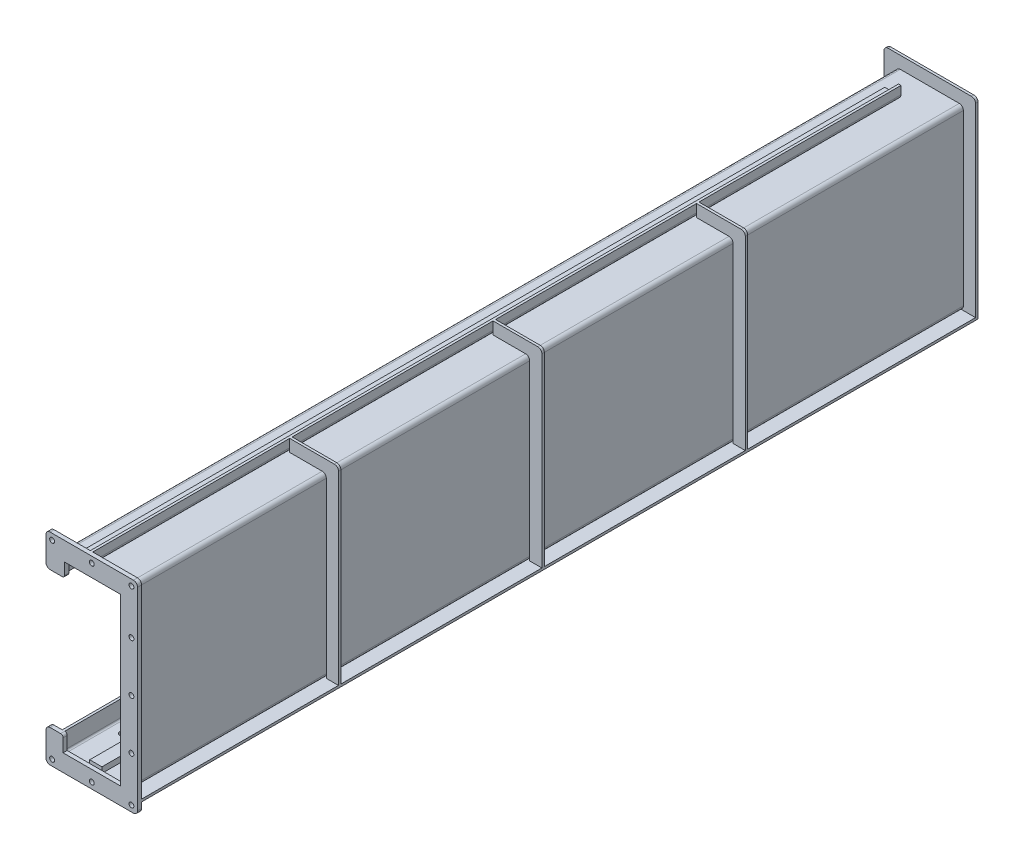
from build123d import *

# Parameters (mm, degrees)
EXTRUDE_1_DEPTH     = 2050
EXTRUDE_2_DEPTH     = 10
SKETCH_3_W          = 40
SKETCH_3_H          = 1986.707861461
EXTRUDE_3_DEPTH     = 6
SKETCH_4_W          = 6
SKETCH_4_H          = 1986.707861461
EXTRUDE_4_DEPTH     = 24
FILLET_1_R          = 4
FILLET_2_R          = 10
EXTRUDE_5_DEPTH     = 6
EXTRUDE_6_DEPTH     = 6
EXTRUDE_7_DEPTH     = 6
EXTRUDE_8_DEPTH     = 6
SKETCH_9_W          = 180
SKETCH_9_H          = 2056
EXTRUDE_9_DEPTH     = 6
SKETCH_10_W         = 30
SKETCH_10_H         = 14
EXTRUDE_10_DEPTH    = 2056
FILLET_3_R          = 10
FILLET_4_R          = 6
CUT_EXTRUDE_1_REACH = 38
SKETCH_11_R         = 7
SKETCH_12_R         = 6
SKETCH_12_W         = 5695
SKETCH_12_H         = 334
CUT_EXTRUDE_2_DEPTH = 10


with BuildPart() as part:
    # 草图1 → 凸台-拉伸1 (new body)
    with BuildSketch(Plane.XY):
        with BuildLine():
            Line((0, 10), (0, 426))
            ThreePointArc((0, 426), (-2.928932188, 433.071067812), (-10, 436))
            Line((-10, 436), (-155, 436))
            ThreePointArc((-155, 436), (-162.071067812, 433.071067812), (-165, 426))
            Line((-165, 426), (-165, 386))
            Line((-165, 386), (-159, 386))
            Line((-159, 386), (-159, 426))
            ThreePointArc((-159, 426), (-157.828427125, 428.828427125), (-155, 430))
            Line((-155, 430), (-10, 430))
            ThreePointArc((-10, 430), (-7.171572875, 428.828427125), (-6, 426))
            Line((-6, 426), (-6, 10))
            ThreePointArc((-6, 10), (-7.171572875, 7.171572875), (-10, 6))
            Line((-10, 6), (-155, 6))
            ThreePointArc((-155, 6), (-157.828427125, 7.171572875), (-159, 10))
            Line((-159, 10), (-159, 50))
            Line((-159, 50), (-165, 50))
            Line((-165, 50), (-165, 10))
            ThreePointArc((-165, 10), (-162.071067812, 2.928932188), (-155, 0))
            Line((-155, 0), (-10, 0))
            ThreePointArc((-10, 0), (-2.928932188, 2.928932188), (0, 10))
        make_face()
    extrude(amount=EXTRUDE_1_DEPTH)



with BuildPart() as body_2:
    # 草图2 → 凸台-拉伸2 (new body)
    with BuildSketch(Plane.XY.offset(2050)):
        with BuildLine():
            Line((-153, 50), (-195, 50))
            Line((-195, 50), (-195, -20))
            ThreePointArc((-195, -20), (-192.071067812, -27.071067812), (-185, -30))
            Line((-185, -30), (20, -30))
            ThreePointArc((20, -30), (27.071067812, -27.071067812), (30, -20))
            Line((30, -20), (30, 456))
            ThreePointArc((30, 456), (27.071067812, 463.071067812), (20, 466))
            Line((20, 466), (-185.000001669, 466))
            ThreePointArc((-185.000001669, 466), (-192.071069481, 463.071067812), (-195.000001669, 456))
            Line((-195.000001669, 456), (-195.000001669, 386))
            Line((-195.000001669, 386), (-149, 386))
            Line((-149, 386), (-149, 420))
            Line((-149, 420), (-12, 420))
            Line((-12, 420), (-12, 12))
            Line((-12, 12), (-153, 12))
            Line((-153, 12), (-153, 50))
        make_face()
    extrude(amount=EXTRUDE_2_DEPTH)



with BuildPart() as body_3:
    # 草图3 → 凸台-拉伸3 (new body)
    with BuildSketch(Plane(origin=(0, 436, 0), x_dir=(1, 0, 0), z_dir=(0, 1, 0))):
        with Locations((-110, -1056.64606927)):
            Rectangle(SKETCH_3_W, SKETCH_3_H)
    extrude(amount=EXTRUDE_3_DEPTH)


with BuildPart() as body_2_1:
    add(body_2.part)

    add(body_3.part)  # 凸台-拉伸4 merges body 3
    # 草图4 → 凸台-拉伸4 (add)
    with BuildSketch(Plane(origin=(0, 442, 0), x_dir=(1, 0, 0), z_dir=(0, 1, 0))):
        with Locations((-93, -1056.64606927)):
            Rectangle(SKETCH_4_W, SKETCH_4_H)
    extrude(amount=EXTRUDE_4_DEPTH)

    # 圆角1
    fillet_1_edges = [body_2_1.edges().sort_by_distance(p)[0] for p in [
        (-96, 442, 1056.64606927),
    ]]
    fillet(fillet_1_edges, radius=FILLET_1_R)

    # 圆角2
    fillet_2_edges = [body_2_1.edges().sort_by_distance(p)[0] for p in [
        (-90, 436, 1056.64606927),
    ]]
    fillet(fillet_2_edges, radius=FILLET_2_R)


with BuildPart() as part_1:
    add(part.part)

    add(body_2_1.part)  # 凸台-拉伸5 merges body 2
    # 草图5 → 凸台-拉伸5 (add)
    with BuildSketch(Plane.XY.offset(1560)):
        with BuildLine():
            Line((0, 0), (30, 0))
            Line((30, 0), (30, 456))
            ThreePointArc((30, 456), (27.071067812, 463.071067812), (20, 466))
            Line((20, 466), (-90, 466))
            Line((-90, 466), (-90, 436))
            Line((-90, 436), (-10, 436))
            ThreePointArc((-10, 436), (-2.928932188, 433.071067812), (0, 426))
            Line((0, 426), (0, 0))
        make_face()
    extrude(amount=EXTRUDE_5_DEPTH)

    # 草图6 → 凸台-拉伸6 (add)
    with BuildSketch(Plane.XY.offset(1060)):
        with BuildLine():
            Line((-90, 436), (-10, 436))
            ThreePointArc((-10, 436), (-2.928932188, 433.071067812), (0, 426))
            Line((0, 426), (0, 10))
            Line((0, 10), (0, 0))
            Line((0, 0), (30, 0))
            Line((30, 0), (30, 456))
            ThreePointArc((30, 456), (27.071067812, 463.071067812), (20, 466))
            Line((20, 466), (-90, 466))
            Line((-90, 466), (-90, 446))
            Line((-90, 446), (-90, 436))
        make_face()
    extrude(amount=EXTRUDE_6_DEPTH)

    # 草图7 → 凸台-拉伸7 (add)
    with BuildSketch(Plane.XY.offset(560)):
        with BuildLine():
            Line((0, 426), (0, 10))
            Line((0, 10), (0, 0))
            Line((0, 0), (30, 0))
            Line((30, 0), (30, 456))
            ThreePointArc((30, 456), (27.071067812, 463.071067812), (20, 466))
            Line((20, 466), (-90, 466))
            Line((-90, 466), (-90, 446))
            Line((-90, 446), (-90, 436))
            Line((-90, 436), (-10, 436))
            ThreePointArc((-10, 436), (-2.928932188, 433.071067812), (0, 426))
        make_face()
    extrude(amount=EXTRUDE_7_DEPTH)

    # 草图8 → 凸台-拉伸8 (add)
    with BuildSketch(Plane(origin=(0, 0, 0), x_dir=(-1, 0, 0), z_dir=(0, 0, -1))):
        with BuildLine():
            Line((0, 0), (-30, 0))
            Line((-30, 0), (-30, 456))
            ThreePointArc((-30, 456), (-27.071067812, 463.071067812), (-20, 466))
            Line((-20, 466), (185.000001669, 466))
            ThreePointArc((185.000001669, 466), (192.071069481, 463.071067812), (195.000001669, 456))
            Line((195.000001669, 456), (195.000001669, 386))
            Line((195.000001669, 386), (149, 386))
            Line((149, 386), (149, 420))
            Line((149, 420), (12, 420))
            Line((12, 420), (12, 12))
            Line((12, 12), (153, 12))
            Line((153, 12), (153, 50))
            Line((153, 50), (195, 50))
            Line((195, 50), (195, 0))
            Line((195, 0), (0, 0))
        make_face()
    extrude(amount=EXTRUDE_8_DEPTH)

    # 草图9 → 凸台-拉伸9 (add)
    with BuildSketch(Plane.XZ):
        with Locations((-60, 1022)):
            Rectangle(SKETCH_9_W, SKETCH_9_H)
    extrude(amount=EXTRUDE_9_DEPTH)

    # 草图10 → 凸台-拉伸10 (add)
    with BuildSketch(Plane.XY.offset(2050)):
        with Locations((-82.5, 423)):
            Rectangle(SKETCH_10_W, SKETCH_10_H)
        with Locations((-82.5, 13)):
            Rectangle(SKETCH_10_W, SKETCH_10_H)
    extrude(amount=-EXTRUDE_10_DEPTH)

    # 圆角3
    fillet_3_edges = [part_1.edges().sort_by_distance(p)[0] for p in [
        (-195, 50, 2055),
        (-195.000001669, 386, 2055),
    ]]
    fillet(fillet_3_edges, radius=FILLET_3_R)

    # 圆角4
    fillet_4_edges = [part_1.edges().sort_by_distance(p)[0] for p in [
        (-153, 50, 2055),
        (-149, 386, 2055),
    ]]
    fillet(fillet_4_edges, radius=FILLET_4_R)

    # 草图11 → 切除-拉伸1 (cut, up to next)
    with BuildSketch(Plane(origin=(0, 6, 0), x_dir=(1, 0, 0), z_dir=(0, 1, 0)), mode=Mode.PRIVATE) as cut_extrude_1_sk1:
        with Locations((-37.5, -1940)):
            Circle(SKETCH_11_R)
    cut_extrude_1_tool1 = extrude(cut_extrude_1_sk1.sketch, amount=-CUT_EXTRUDE_1_REACH, mode=Mode.PRIVATE) & part_1.part
    add(cut_extrude_1_tool1.solids().sort_by_distance((-37.5, 6, 1940))[0], mode=Mode.SUBTRACT)
    # 草图11 → 切除-拉伸1 (cut, up to next)
    with BuildSketch(Plane(origin=(0, 6, 0), x_dir=(1, 0, 0), z_dir=(0, 1, 0)), mode=Mode.PRIVATE) as cut_extrude_1_sk2:
        with Locations((-127.5, -1940)):
            Circle(SKETCH_11_R)
    cut_extrude_1_tool2 = extrude(cut_extrude_1_sk2.sketch, amount=-CUT_EXTRUDE_1_REACH, mode=Mode.PRIVATE) & part_1.part
    add(cut_extrude_1_tool2.solids().sort_by_distance((-127.5, 6, 1940))[0], mode=Mode.SUBTRACT)
    # 草图11 → 切除-拉伸1 (cut, up to next)
    with BuildSketch(Plane(origin=(0, 6, 0), x_dir=(1, 0, 0), z_dir=(0, 1, 0)), mode=Mode.PRIVATE) as cut_extrude_1_sk3:
        with Locations((-37.5, -1700)):
            Circle(SKETCH_11_R)
    cut_extrude_1_tool3 = extrude(cut_extrude_1_sk3.sketch, amount=-CUT_EXTRUDE_1_REACH, mode=Mode.PRIVATE) & part_1.part
    add(cut_extrude_1_tool3.solids().sort_by_distance((-37.5, 6, 1700))[0], mode=Mode.SUBTRACT)
    # 草图11 → 切除-拉伸1 (cut, up to next)
    with BuildSketch(Plane(origin=(0, 6, 0), x_dir=(1, 0, 0), z_dir=(0, 1, 0)), mode=Mode.PRIVATE) as cut_extrude_1_sk4:
        with Locations((-127.5, -1700)):
            Circle(SKETCH_11_R)
    cut_extrude_1_tool4 = extrude(cut_extrude_1_sk4.sketch, amount=-CUT_EXTRUDE_1_REACH, mode=Mode.PRIVATE) & part_1.part
    add(cut_extrude_1_tool4.solids().sort_by_distance((-127.5, 6, 1700))[0], mode=Mode.SUBTRACT)
    # 草图11 → 切除-拉伸1 (cut, up to next)
    with BuildSketch(Plane(origin=(0, 6, 0), x_dir=(1, 0, 0), z_dir=(0, 1, 0)), mode=Mode.PRIVATE) as cut_extrude_1_sk5:
        with Locations((-37.5, -1460)):
            Circle(SKETCH_11_R)
    cut_extrude_1_tool5 = extrude(cut_extrude_1_sk5.sketch, amount=-CUT_EXTRUDE_1_REACH, mode=Mode.PRIVATE) & part_1.part
    add(cut_extrude_1_tool5.solids().sort_by_distance((-37.5, 6, 1460))[0], mode=Mode.SUBTRACT)
    # 草图11 → 切除-拉伸1 (cut, up to next)
    with BuildSketch(Plane(origin=(0, 6, 0), x_dir=(1, 0, 0), z_dir=(0, 1, 0)), mode=Mode.PRIVATE) as cut_extrude_1_sk6:
        with Locations((-127.5, -1460)):
            Circle(SKETCH_11_R)
    cut_extrude_1_tool6 = extrude(cut_extrude_1_sk6.sketch, amount=-CUT_EXTRUDE_1_REACH, mode=Mode.PRIVATE) & part_1.part
    add(cut_extrude_1_tool6.solids().sort_by_distance((-127.5, 6, 1460))[0], mode=Mode.SUBTRACT)
    # 草图11 → 切除-拉伸1 (cut, up to next)
    with BuildSketch(Plane(origin=(0, 6, 0), x_dir=(1, 0, 0), z_dir=(0, 1, 0)), mode=Mode.PRIVATE) as cut_extrude_1_sk7:
        with Locations((-37.5, -1220)):
            Circle(SKETCH_11_R)
    cut_extrude_1_tool7 = extrude(cut_extrude_1_sk7.sketch, amount=-CUT_EXTRUDE_1_REACH, mode=Mode.PRIVATE) & part_1.part
    add(cut_extrude_1_tool7.solids().sort_by_distance((-37.5, 6, 1220))[0], mode=Mode.SUBTRACT)
    # 草图11 → 切除-拉伸1 (cut, up to next)
    with BuildSketch(Plane(origin=(0, 6, 0), x_dir=(1, 0, 0), z_dir=(0, 1, 0)), mode=Mode.PRIVATE) as cut_extrude_1_sk8:
        with Locations((-127.5, -1220)):
            Circle(SKETCH_11_R)
    cut_extrude_1_tool8 = extrude(cut_extrude_1_sk8.sketch, amount=-CUT_EXTRUDE_1_REACH, mode=Mode.PRIVATE) & part_1.part
    add(cut_extrude_1_tool8.solids().sort_by_distance((-127.5, 6, 1220))[0], mode=Mode.SUBTRACT)
    # 草图11 → 切除-拉伸1 (cut, up to next)
    with BuildSketch(Plane(origin=(0, 6, 0), x_dir=(1, 0, 0), z_dir=(0, 1, 0)), mode=Mode.PRIVATE) as cut_extrude_1_sk9:
        with Locations((-37.5, -980)):
            Circle(SKETCH_11_R)
    cut_extrude_1_tool9 = extrude(cut_extrude_1_sk9.sketch, amount=-CUT_EXTRUDE_1_REACH, mode=Mode.PRIVATE) & part_1.part
    add(cut_extrude_1_tool9.solids().sort_by_distance((-37.5, 6, 980))[0], mode=Mode.SUBTRACT)
    # 草图11 → 切除-拉伸1 (cut, up to next)
    with BuildSketch(Plane(origin=(0, 6, 0), x_dir=(1, 0, 0), z_dir=(0, 1, 0)), mode=Mode.PRIVATE) as cut_extrude_1_sk10:
        with Locations((-127.5, -980)):
            Circle(SKETCH_11_R)
    cut_extrude_1_tool10 = extrude(cut_extrude_1_sk10.sketch, amount=-CUT_EXTRUDE_1_REACH, mode=Mode.PRIVATE) & part_1.part
    add(cut_extrude_1_tool10.solids().sort_by_distance((-127.5, 6, 980))[0], mode=Mode.SUBTRACT)
    # 草图11 → 切除-拉伸1 (cut, up to next)
    with BuildSketch(Plane(origin=(0, 6, 0), x_dir=(1, 0, 0), z_dir=(0, 1, 0)), mode=Mode.PRIVATE) as cut_extrude_1_sk11:
        with Locations((-37.5, -740)):
            Circle(SKETCH_11_R)
    cut_extrude_1_tool11 = extrude(cut_extrude_1_sk11.sketch, amount=-CUT_EXTRUDE_1_REACH, mode=Mode.PRIVATE) & part_1.part
    add(cut_extrude_1_tool11.solids().sort_by_distance((-37.5, 6, 740))[0], mode=Mode.SUBTRACT)
    # 草图11 → 切除-拉伸1 (cut, up to next)
    with BuildSketch(Plane(origin=(0, 6, 0), x_dir=(1, 0, 0), z_dir=(0, 1, 0)), mode=Mode.PRIVATE) as cut_extrude_1_sk12:
        with Locations((-127.5, -740)):
            Circle(SKETCH_11_R)
    cut_extrude_1_tool12 = extrude(cut_extrude_1_sk12.sketch, amount=-CUT_EXTRUDE_1_REACH, mode=Mode.PRIVATE) & part_1.part
    add(cut_extrude_1_tool12.solids().sort_by_distance((-127.5, 6, 740))[0], mode=Mode.SUBTRACT)
    # 草图11 → 切除-拉伸1 (cut, up to next)
    with BuildSketch(Plane(origin=(0, 6, 0), x_dir=(1, 0, 0), z_dir=(0, 1, 0)), mode=Mode.PRIVATE) as cut_extrude_1_sk13:
        with Locations((-37.5, -500)):
            Circle(SKETCH_11_R)
    cut_extrude_1_tool13 = extrude(cut_extrude_1_sk13.sketch, amount=-CUT_EXTRUDE_1_REACH, mode=Mode.PRIVATE) & part_1.part
    add(cut_extrude_1_tool13.solids().sort_by_distance((-37.5, 6, 500))[0], mode=Mode.SUBTRACT)
    # 草图11 → 切除-拉伸1 (cut, up to next)
    with BuildSketch(Plane(origin=(0, 6, 0), x_dir=(1, 0, 0), z_dir=(0, 1, 0)), mode=Mode.PRIVATE) as cut_extrude_1_sk14:
        with Locations((-127.5, -500)):
            Circle(SKETCH_11_R)
    cut_extrude_1_tool14 = extrude(cut_extrude_1_sk14.sketch, amount=-CUT_EXTRUDE_1_REACH, mode=Mode.PRIVATE) & part_1.part
    add(cut_extrude_1_tool14.solids().sort_by_distance((-127.5, 6, 500))[0], mode=Mode.SUBTRACT)
    # 草图11 → 切除-拉伸1 (cut, up to next)
    with BuildSketch(Plane(origin=(0, 6, 0), x_dir=(1, 0, 0), z_dir=(0, 1, 0)), mode=Mode.PRIVATE) as cut_extrude_1_sk15:
        with Locations((-37.5, -260)):
            Circle(SKETCH_11_R)
    cut_extrude_1_tool15 = extrude(cut_extrude_1_sk15.sketch, amount=-CUT_EXTRUDE_1_REACH, mode=Mode.PRIVATE) & part_1.part
    add(cut_extrude_1_tool15.solids().sort_by_distance((-37.5, 6, 260))[0], mode=Mode.SUBTRACT)
    # 草图11 → 切除-拉伸1 (cut, up to next)
    with BuildSketch(Plane(origin=(0, 6, 0), x_dir=(1, 0, 0), z_dir=(0, 1, 0)), mode=Mode.PRIVATE) as cut_extrude_1_sk16:
        with Locations((-127.5, -260)):
            Circle(SKETCH_11_R)
    cut_extrude_1_tool16 = extrude(cut_extrude_1_sk16.sketch, amount=-CUT_EXTRUDE_1_REACH, mode=Mode.PRIVATE) & part_1.part
    add(cut_extrude_1_tool16.solids().sort_by_distance((-127.5, 6, 260))[0], mode=Mode.SUBTRACT)
    # 草图11 → 切除-拉伸1 (cut, up to next)
    with BuildSketch(Plane(origin=(0, 6, 0), x_dir=(1, 0, 0), z_dir=(0, 1, 0)), mode=Mode.PRIVATE) as cut_extrude_1_sk17:
        with Locations((-37.5, -20)):
            Circle(SKETCH_11_R)
    cut_extrude_1_tool17 = extrude(cut_extrude_1_sk17.sketch, amount=-CUT_EXTRUDE_1_REACH, mode=Mode.PRIVATE) & part_1.part
    add(cut_extrude_1_tool17.solids().sort_by_distance((-37.5, 6, 20))[0], mode=Mode.SUBTRACT)
    # 草图11 → 切除-拉伸1 (cut, up to next)
    with BuildSketch(Plane(origin=(0, 6, 0), x_dir=(1, 0, 0), z_dir=(0, 1, 0)), mode=Mode.PRIVATE) as cut_extrude_1_sk18:
        with Locations((-127.5, -20)):
            Circle(SKETCH_11_R)
    cut_extrude_1_tool18 = extrude(cut_extrude_1_sk18.sketch, amount=-CUT_EXTRUDE_1_REACH, mode=Mode.PRIVATE) & part_1.part
    add(cut_extrude_1_tool18.solids().sort_by_distance((-127.5, 6, 20))[0], mode=Mode.SUBTRACT)

    # 草图12 → 切除-拉伸2 (cut)
    with BuildSketch(Plane.XY.offset(2060)):
        with Locations((-180.000001669, 451)):
            Circle(SKETCH_12_R)
        with Locations((-82.500000835, 451)):
            Circle(SKETCH_12_R)
        with Locations((15, 451)):
            Circle(SKETCH_12_R)
        with Locations((15, 341)):
            Circle(SKETCH_12_R)
        with Locations((15, 95)):
            Circle(SKETCH_12_R)
        with Locations((15, 218)):
            Circle(SKETCH_12_R)
        with Locations((15, -15)):
            Circle(SKETCH_12_R)
        with Locations((-82.5, -15)):
            Circle(SKETCH_12_R)
        with Locations((-180.000001669, -15)):
            Circle(SKETCH_12_R)
        with Locations((-2907.561200019, -255)):
            Rectangle(SKETCH_12_W, SKETCH_12_H)
    extrude(amount=-CUT_EXTRUDE_2_DEPTH, mode=Mode.SUBTRACT)


solid = part_1.part
